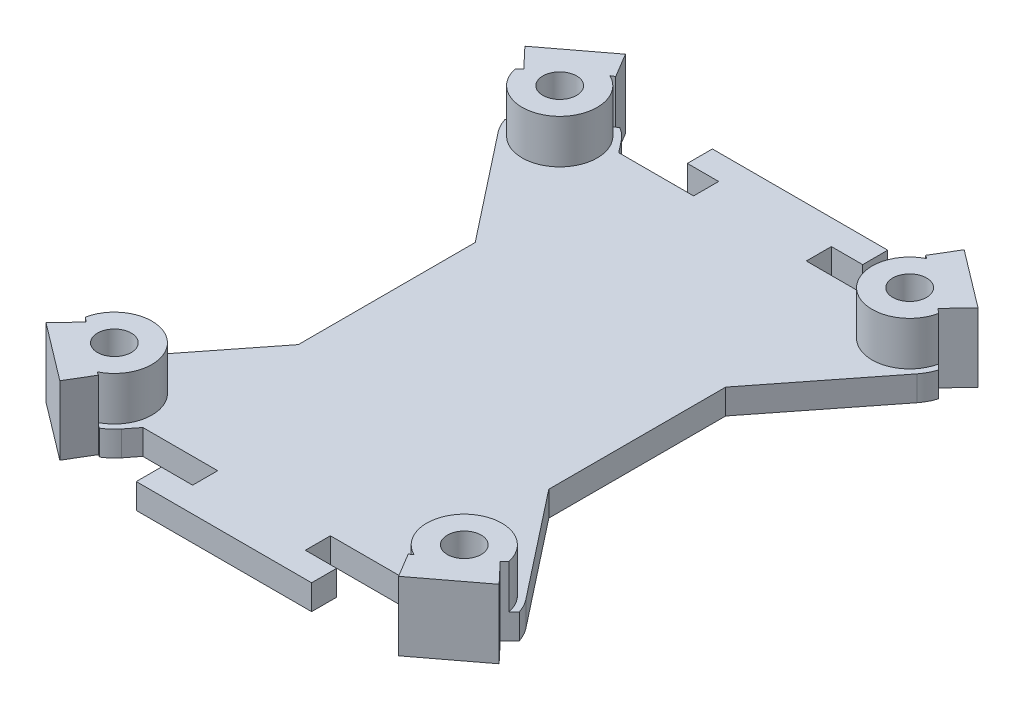
from build123d import *

# Parameters (mm, degrees)
SKETCH1_R               = 24.07
BOSS_EXTRUDE1_DEPTH     = 2
BOSS_EXTRUDE2_DEPTH     = 5.5
BOSS_EXTRUDE5_REACH     = 36.482
SKETCH2_R               = 3
SKETCH1_5_R             = 34.31362745
CUT_EXTRUDE3_DEPTH      = 35.48158639
CUT_EXTRUDE3_DEPTH_BACK = 35.48158639
M2_5_CLEARANCE_HOLE1_D  = 2.7
CUT_EXTRUDE4_DEPTH      = 35.48158639


with BuildPart() as part:
    # Sketch1 → Boss-Extrude1 (new body)
    with BuildSketch(Plane(origin=(0, 0, 0), x_dir=(1, 0, 0), z_dir=(0, 1, 0))):
        with Locations(Location((0, 0, 0), (0, 0, 270))):
            Circle(SKETCH1_R)
    extrude(amount=BOSS_EXTRUDE1_DEPTH)

    # Sketch1_3 → Boss-Extrude2 (add)
    with BuildSketch(Plane(origin=(0, 0, 0), x_dir=(1, 0, 0), z_dir=(0, 1, 0))):
        with BuildLine():
            ThreePointArc((12.366915807, 20.650043424), (14.541516735, 19.180959075), (16.543257949, 17.483864459))
            Line((16.543257949, 17.483864459), (18.089781085, 19.118318867))
            Line((18.089781085, 19.118318867), (13.523019488, 22.580483607))
            Line((13.523019488, 22.580483607), (12.366915807, 20.650043424))
        make_face()
        with BuildLine():
            ThreePointArc((16.543257949, -17.483864459), (14.541516735, -19.180959075), (12.366915807, -20.650043424))
            Line((12.366915807, -20.650043424), (13.523019488, -22.580483607))
            Line((13.523019488, -22.580483607), (18.089781085, -19.118318867))
            Line((18.089781085, -19.118318867), (16.543257949, -17.483864459))
        make_face()
        with BuildLine():
            ThreePointArc((-16.543257949, 17.483864459), (-14.541516735, 19.180959075), (-12.366915807, 20.650043424))
            Line((-12.366915807, 20.650043424), (-13.523019488, 22.580483607))
            Line((-13.523019488, 22.580483607), (-18.089781085, 19.118318867))
            Line((-18.089781085, 19.118318867), (-16.543257949, 17.483864459))
        make_face()
        with BuildLine():
            ThreePointArc((-12.366915807, -20.650043424), (-14.541516735, -19.180959075), (-16.543257949, -17.483864459))
            Line((-16.543257949, -17.483864459), (-18.089781085, -19.118318867))
            Line((-18.089781085, -19.118318867), (-13.523019488, -22.580483607))
            Line((-13.523019488, -22.580483607), (-12.366915807, -20.650043424))
        make_face()
    extrude(amount=BOSS_EXTRUDE2_DEPTH)

    # Boss-Extrude5: up to this face of the body (flat: up to its plane)
    boss_extrude5_end = Plane(part.part.faces().sort_by_distance((15.168468653, 5.5, 20.00793877))[0])
    # Sketch2 → Boss-Extrude5 (add, up to the picked face)
    with BuildSketch(Plane(origin=(0, 0, 0), x_dir=(1, 0, 0), z_dir=(0, 1, 0)), mode=Mode.PRIVATE) as boss_extrude5_sk1:
        with Locations((13.97, 17.78)):
            Circle(SKETCH2_R)
    boss_extrude5_tool1 = split(extrude(boss_extrude5_sk1.sketch, amount=BOSS_EXTRUDE5_REACH, mode=Mode.PRIVATE), bisect_by=boss_extrude5_end, keep=Keep.BOTH, mode=Mode.PRIVATE)
    # Sketch2 → Boss-Extrude5 (add, up to the picked face)
    with BuildSketch(Plane(origin=(0, 0, 0), x_dir=(1, 0, 0), z_dir=(0, 1, 0)), mode=Mode.PRIVATE) as boss_extrude5_sk2:
        with Locations((13.97, -17.78)):
            Circle(SKETCH2_R)
    boss_extrude5_tool2 = split(extrude(boss_extrude5_sk2.sketch, amount=BOSS_EXTRUDE5_REACH, mode=Mode.PRIVATE), bisect_by=boss_extrude5_end, keep=Keep.BOTH, mode=Mode.PRIVATE)
    # Sketch2 → Boss-Extrude5 (add, up to the picked face)
    with BuildSketch(Plane(origin=(0, 0, 0), x_dir=(1, 0, 0), z_dir=(0, 1, 0)), mode=Mode.PRIVATE) as boss_extrude5_sk3:
        with Locations((-13.97, -17.78)):
            Circle(SKETCH2_R)
    boss_extrude5_tool3 = split(extrude(boss_extrude5_sk3.sketch, amount=BOSS_EXTRUDE5_REACH, mode=Mode.PRIVATE), bisect_by=boss_extrude5_end, keep=Keep.BOTH, mode=Mode.PRIVATE)
    # Sketch2 → Boss-Extrude5 (add, up to the picked face)
    with BuildSketch(Plane(origin=(0, 0, 0), x_dir=(1, 0, 0), z_dir=(0, 1, 0)), mode=Mode.PRIVATE) as boss_extrude5_sk4:
        with Locations((-13.97, 17.78)):
            Circle(SKETCH2_R)
    boss_extrude5_tool4 = split(extrude(boss_extrude5_sk4.sketch, amount=BOSS_EXTRUDE5_REACH, mode=Mode.PRIVATE), bisect_by=boss_extrude5_end, keep=Keep.BOTH, mode=Mode.PRIVATE)
    add(boss_extrude5_tool1.solids().sort_by(Axis((13.97, 0, -17.78), (0, 1, 0)))[0])
    add(boss_extrude5_tool2.solids().sort_by(Axis((13.97, 0, 17.78), (0, 1, 0)))[0])
    add(boss_extrude5_tool3.solids().sort_by(Axis((-13.97, 0, 17.78), (0, 1, 0)))[0])
    add(boss_extrude5_tool4.solids().sort_by(Axis((-13.97, 0, -17.78), (0, 1, 0)))[0])

    # Sketch1_5 → Cut-Extrude3 (cut, two sides)
    with BuildSketch(Plane(origin=(0, 0, 0), x_dir=(1, 0, 0), z_dir=(0, 1, 0))) as cut_extrude3_sk:
        Circle(SKETCH1_5_R)
        with BuildLine():
            Line((18.089781085, 19.118318867), (16.543257949, 17.483864459))
            ThreePointArc((16.543257949, 17.483864459), (22.108382108, 9.517580605), (24.07, 0))
            ThreePointArc((24.07, 0), (22.108382108, -9.517580605), (16.543257949, -17.483864459))
            Line((16.543257949, -17.483864459), (18.089781085, -19.118318867))
            Line((18.089781085, -19.118318867), (13.523019488, -22.580483607))
            Line((13.523019488, -22.580483607), (12.366915807, -20.650043424))
            ThreePointArc((12.366915807, -20.650043424), (0, -24.07), (-12.366915807, -20.650043424))
            Line((-12.366915807, -20.650043424), (-13.523019488, -22.580483607))
            Line((-13.523019488, -22.580483607), (-18.089781085, -19.118318867))
            Line((-18.089781085, -19.118318867), (-16.543257949, -17.483864459))
            ThreePointArc((-16.543257949, -17.483864459), (-24.07, 0), (-16.543257949, 17.483864459))
            Line((-16.543257949, 17.483864459), (-18.089781085, 19.118318867))
            Line((-18.089781085, 19.118318867), (-13.523019488, 22.580483607))
            Line((-13.523019488, 22.580483607), (-12.366915807, 20.650043424))
            ThreePointArc((-12.366915807, 20.650043424), (0, 24.07), (12.366915807, 20.650043424))
            Line((12.366915807, 20.650043424), (13.523019488, 22.580483607))
            Line((13.523019488, 22.580483607), (18.089781085, 19.118318867))
        make_face(mode=Mode.SUBTRACT)
    extrude(amount=CUT_EXTRUDE3_DEPTH, mode=Mode.SUBTRACT)
    extrude(cut_extrude3_sk.sketch, amount=-CUT_EXTRUDE3_DEPTH_BACK, mode=Mode.SUBTRACT)

    # M2.5 Clearance Hole1 (through all)
    with Locations(Plane(origin=(0, 5.5, 0), x_dir=(1, 0, 0), z_dir=(0, 1, 0))):
        with Locations((-13.97, 17.78), (13.97, 17.78), (13.97, -17.78), (-13.97, -17.78)):
            Hole(M2_5_CLEARANCE_HOLE1_D / 2)

    # Sketch8 → Cut-Extrude4 (cut, through all)
    with BuildSketch(Plane.XZ):
        with BuildLine():
            ThreePointArc((-12.157407277, 20.77407876), (-11.650071144, 20.400673597), (-11.217885814, 19.942375432))
            Line((-11.217885814, 19.942375432), (-10.477447975, 19))
            Line((-10.477447975, 19), (-4.5, 19))
            Line((-4.5, 19), (-4.5, 21))
            Line((-4.5, 21), (-7, 21))
            Line((-7, 21), (-7, 23))
            Line((-7, 23), (7, 23))
            Line((7, 23), (7, 21))
            Line((7, 21), (4.5, 21))
            Line((4.5, 21), (4.5, 19))
            Line((4.5, 19), (10.477447975, 19))
            Line((10.477447975, 19), (11.217885814, 19.942375432))
            ThreePointArc((11.217885814, 19.942375432), (11.650071144, 20.400673597), (12.157407277, 20.77407876))
            ThreePointArc((12.157407277, 20.77407876), (0, 24.07), (-12.157407277, 20.77407876))
        make_face()
        with BuildLine():
            Line((10, 7.062206513), (10, -7.062206513))
            Line((10, -7.062206513), (16.722114186, -15.617624568))
            ThreePointArc((16.722114186, -15.617624568), (17.065148682, -16.145969817), (17.307920228, -16.727247155))
            ThreePointArc((17.307920228, -16.727247155), (24.07, 0), (17.307920228, 16.727247155))
            ThreePointArc((17.307920228, 16.727247155), (17.065148682, 16.145969817), (16.722114186, 15.617624568))
            Line((16.722114186, 15.617624568), (10, 7.062206513))
        make_face()
        with BuildLine():
            Line((-10, -7.062206513), (-10, 7.062206513))
            Line((-10, 7.062206513), (-16.722114186, 15.617624568))
            ThreePointArc((-16.722114186, 15.617624568), (-17.065148682, 16.145969817), (-17.307920228, 16.727247155))
            ThreePointArc((-17.307920228, 16.727247155), (-24.07, 0), (-17.307920228, -16.727247155))
            ThreePointArc((-17.307920228, -16.727247155), (-17.065148682, -16.145969817), (-16.722114186, -15.617624568))
            Line((-16.722114186, -15.617624568), (-10, -7.062206513))
        make_face()
        with BuildLine():
            Line((11.217885814, -19.942375432), (10.477447975, -19))
            Line((10.477447975, -19), (4.5, -19))
            Line((4.5, -19), (4.5, -21))
            Line((4.5, -21), (7, -21))
            Line((7, -21), (7, -23))
            Line((7, -23), (-7, -23))
            Line((-7, -23), (-7, -21))
            Line((-7, -21), (-4.5, -21))
            Line((-4.5, -21), (-4.5, -19))
            Line((-4.5, -19), (-10.477447975, -19))
            Line((-10.477447975, -19), (-11.217885814, -19.942375432))
            ThreePointArc((-11.217885814, -19.942375432), (-11.650071144, -20.400673597), (-12.157407277, -20.77407876))
            ThreePointArc((-12.157407277, -20.77407876), (0, -24.07), (12.157407277, -20.77407876))
            ThreePointArc((12.157407277, -20.77407876), (11.650071144, -20.400673597), (11.217885814, -19.942375432))
        make_face()
    extrude(amount=-CUT_EXTRUDE4_DEPTH, mode=Mode.SUBTRACT)


solid = part.part
